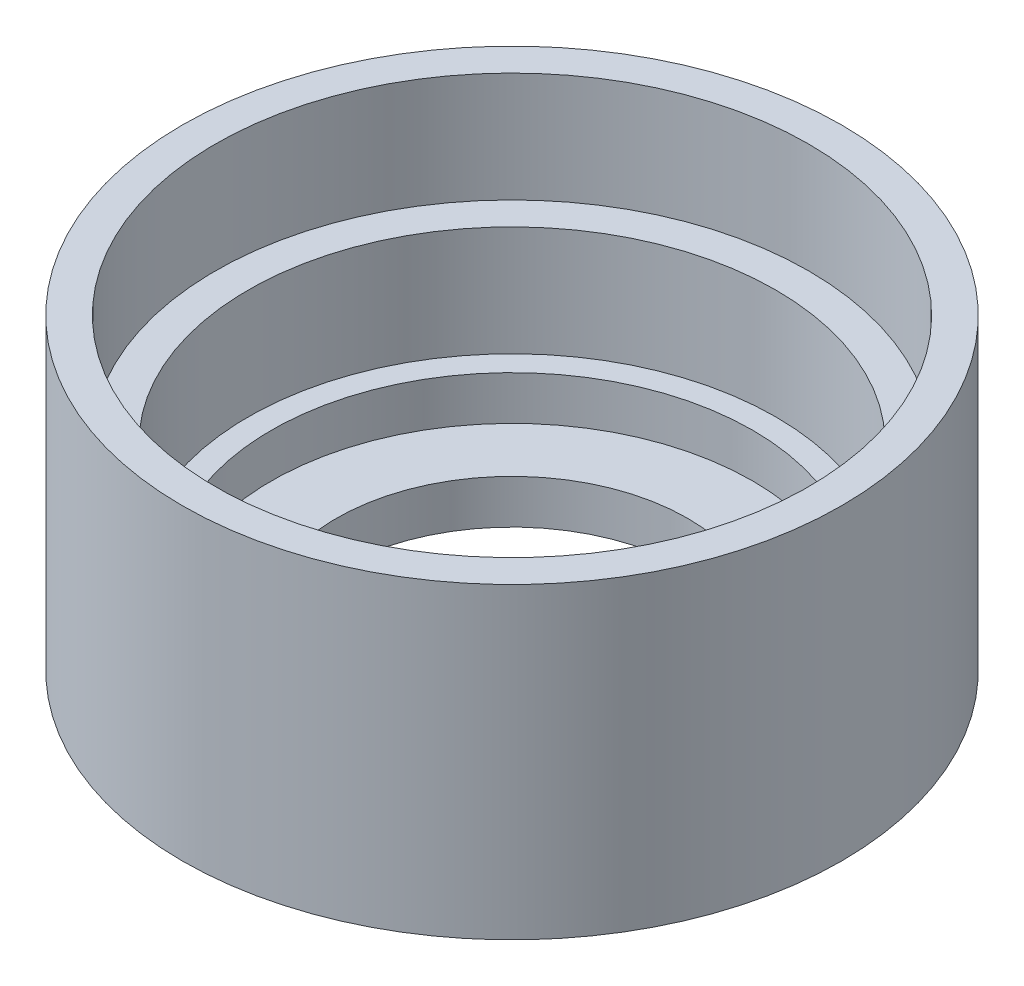
from build123d import *


with BuildPart() as part:
    # 草图1 → 旋转1 (revolve)
    with BuildSketch(Plane.XY):
        Polygon((8, 0), (15, 0), (15, 14), (13.5, 14), (13.5, 9), (12, 9), (12, 4), (10.95, 4), (10.95, 2), (8, 2), align=None)
    revolve(axis=Axis((0, 0, 0), (0, 1, 0)))


solid = part.part
